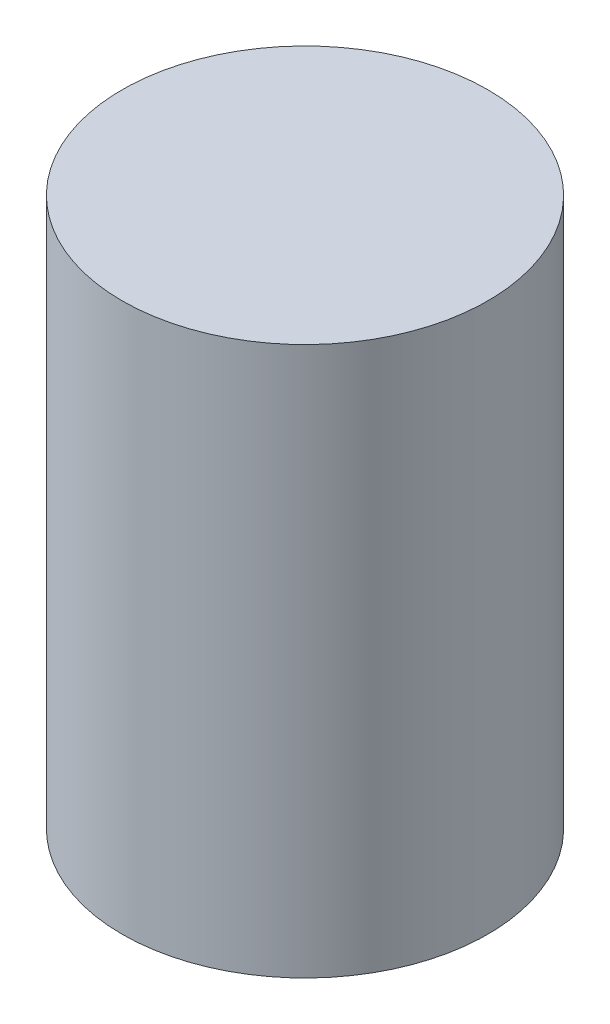
from build123d import *

# Parameters (mm, degrees)
SKETCH1_R           = 500
BOSS_EXTRUDE1_DEPTH = 1500


with BuildPart() as part:
    # Sketch1 → Boss-Extrude1 (new body)
    with BuildSketch(Plane(origin=(0, 0, 0), x_dir=(1, 0, 0), z_dir=(0, 1, 0))):
        Circle(SKETCH1_R)
    extrude(amount=BOSS_EXTRUDE1_DEPTH)


solid = part.part
